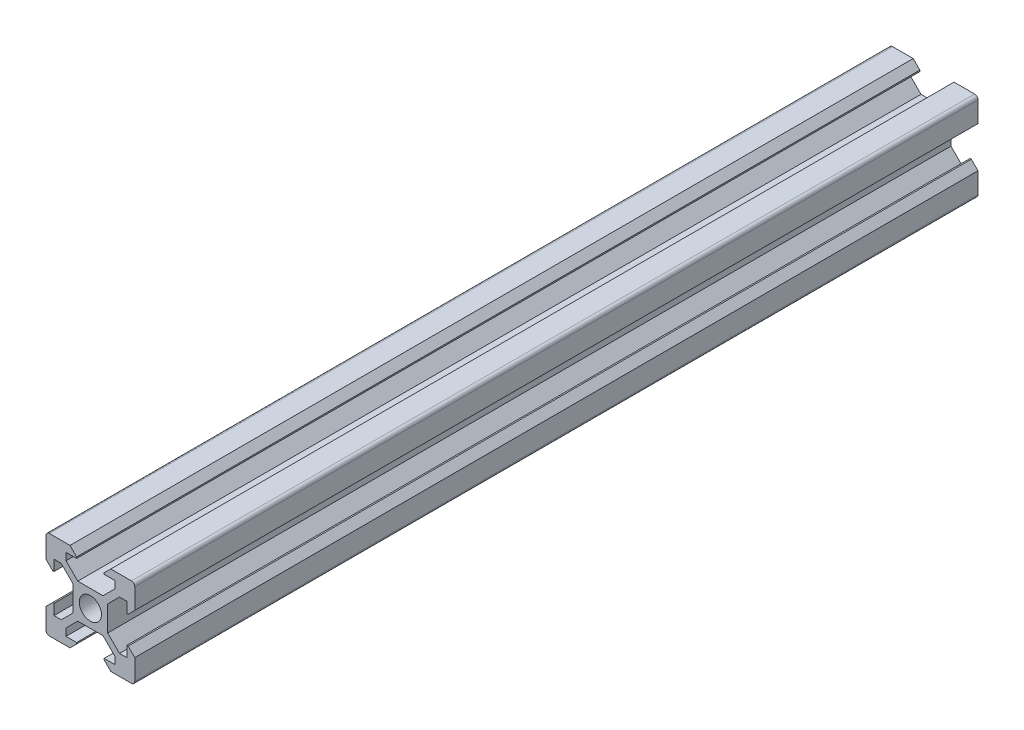
from build123d import *

# Parameters (mm, degrees)
CROQUIS1_R              = 2.5
SALIENTE_EXTRUIR1_DEPTH = 190


with BuildPart() as part:
    # Croquis1 → Saliente-Extruir1 (new body)
    with BuildSketch(Plane.XY):
        with BuildLine():
            Line((-4.6, 10), (-3.1, 8.5))
            Line((-3.1, 8.5), (-3.1, 8.2))
            Line((-3.1, 8.2), (-5.5, 8.2))
            Line((-5.5, 8.2), (-5.5, 6.560660172))
            Line((-5.5, 6.560660172), (-2.84, 3.900660172))
            Line((-2.84, 3.900660172), (0, 3.900660172))
            Line((0, 3.900660172), (2.84, 3.900660172))
            Line((2.84, 3.900660172), (5.5, 6.560660172))
            Line((5.5, 6.560660172), (5.5, 8.2))
            Line((5.5, 8.2), (3.1, 8.2))
            Line((3.1, 8.2), (3.1, 8.5))
            Line((3.1, 8.5), (4.6, 10))
            Line((4.6, 10), (9.25, 10))
            ThreePointArc((9.25, 10), (9.780330086, 9.780330086), (10, 9.25))
            Line((10, 9.25), (10, 4.6))
            Line((10, 4.6), (8.5, 3.1))
            Line((8.5, 3.1), (8.2, 3.1))
            Line((8.2, 3.1), (8.2, 5.5))
            Line((8.2, 5.5), (6.560660172, 5.5))
            Line((6.560660172, 5.5), (3.900660172, 2.84))
            Line((3.900660172, 2.84), (3.900660172, 0))
            Line((3.900660172, 0), (3.900660172, -2.84))
            Line((3.900660172, -2.84), (6.560660172, -5.5))
            Line((6.560660172, -5.5), (8.2, -5.5))
            Line((8.2, -5.5), (8.2, -3.1))
            Line((8.2, -3.1), (8.5, -3.1))
            Line((8.5, -3.1), (10, -4.6))
            Line((10, -4.6), (10, -9.25))
            ThreePointArc((10, -9.25), (9.780330086, -9.780330086), (9.25, -10))
            Line((9.25, -10), (4.6, -10))
            Line((4.6, -10), (3.1, -8.5))
            Line((3.1, -8.5), (3.1, -8.2))
            Line((3.1, -8.2), (5.5, -8.2))
            Line((5.5, -8.2), (5.5, -6.560660172))
            Line((5.5, -6.560660172), (2.84, -3.900660172))
            Line((2.84, -3.900660172), (0, -3.900660172))
            Line((0, -3.900660172), (-2.84, -3.900660172))
            Line((-2.84, -3.900660172), (-5.5, -6.560660172))
            Line((-5.5, -6.560660172), (-5.5, -8.2))
            Line((-5.5, -8.2), (-3.1, -8.2))
            Line((-3.1, -8.2), (-3.1, -8.5))
            Line((-3.1, -8.5), (-4.6, -10))
            Line((-4.6, -10), (-9.25, -10))
            ThreePointArc((-9.25, -10), (-9.780330086, -9.780330086), (-10, -9.25))
            Line((-10, -9.25), (-10, -4.6))
            Line((-10, -4.6), (-8.5, -3.1))
            Line((-8.5, -3.1), (-8.2, -3.1))
            Line((-8.2, -3.1), (-8.2, -5.5))
            Line((-8.2, -5.5), (-6.560660172, -5.5))
            Line((-6.560660172, -5.5), (-3.900660172, -2.84))
            Line((-3.900660172, -2.84), (-3.900660172, 0))
            Line((-3.900660172, 0), (-3.900660172, 2.84))
            Line((-3.900660172, 2.84), (-6.560660172, 5.5))
            Line((-6.560660172, 5.5), (-8.2, 5.5))
            Line((-8.2, 5.5), (-8.2, 3.1))
            Line((-8.2, 3.1), (-8.5, 3.1))
            Line((-8.5, 3.1), (-10, 4.6))
            Line((-10, 4.6), (-10, 9.25))
            ThreePointArc((-10, 9.25), (-9.780330086, 9.780330086), (-9.25, 10))
            Line((-9.25, 10), (-4.6, 10))
        make_face()
        Circle(CROQUIS1_R, mode=Mode.SUBTRACT)
    extrude(amount=SALIENTE_EXTRUIR1_DEPTH)


solid = part.part
